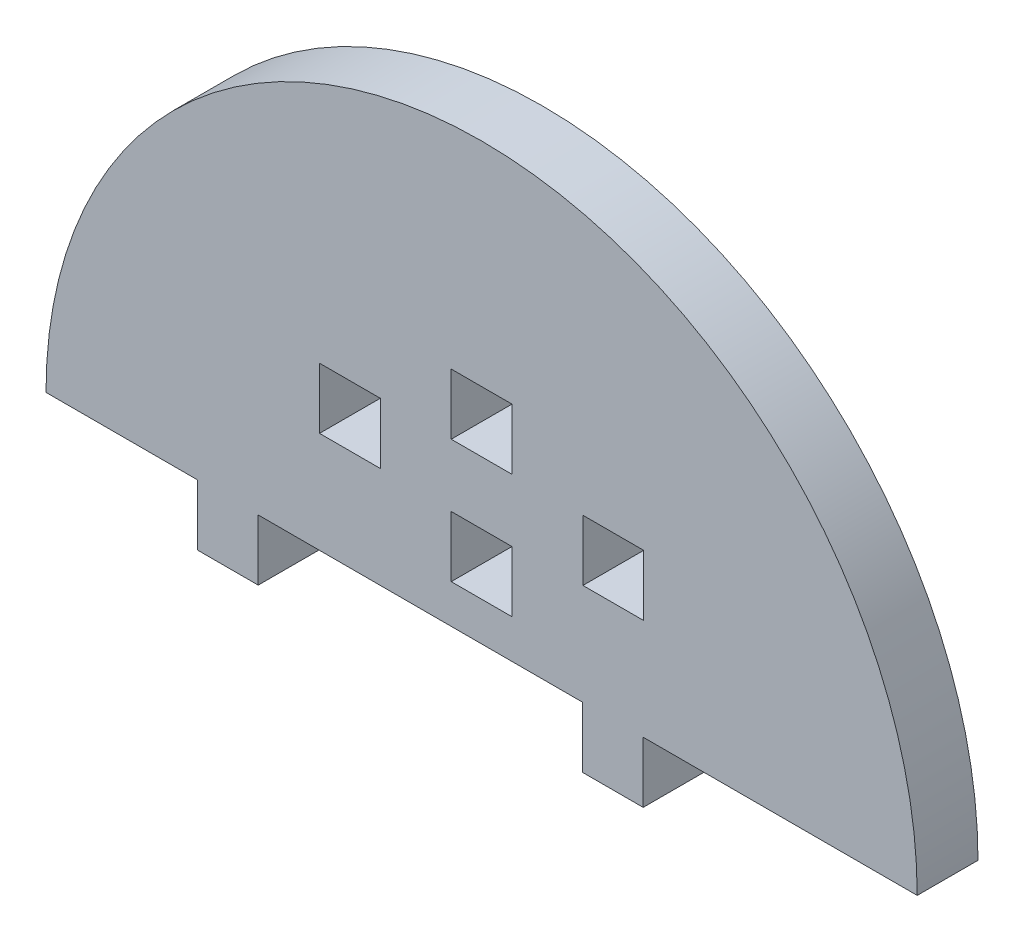
from build123d import *

# Parameters (mm, degrees)
MODEL_W             = 6
MODEL_H             = 6
BOSS_EXTRUDE1_DEPTH = 6


with BuildPart() as part:
    # Model → Boss-Extrude1 (new body)
    with BuildSketch(Plane.XY):
        with BuildLine():
            Line((3463.892984012, 1061.748947436), (3473.892984012, 1061.748947436))
            Line((3473.892984012, 1061.748947436), (3473.892984012, 1055.748947436))
            Line((3473.892984012, 1055.748947436), (3479.892984012, 1055.748947436))
            Line((3479.892984012, 1055.748947436), (3479.892984012, 1061.748947436))
            Line((3479.892984012, 1061.748947436), (3491.892984012, 1061.748947436))
            Line((3491.892984012, 1061.748947436), (3506.94434904, 1061.748947436))
            ThreePointArc((3506.94434904, 1061.748947436), (3463.94434904, 1104.748947436), (3420.94434904, 1061.748947436))
            Line((3420.94434904, 1061.748947436), (3435.892984012, 1061.748947436))
            Line((3435.892984012, 1061.748947436), (3435.892984012, 1055.748947436))
            Line((3435.892984012, 1055.748947436), (3441.892984012, 1055.748947436))
            Line((3441.892984012, 1055.748947436), (3441.892984012, 1061.748947436))
            Line((3441.892984012, 1061.748947436), (3463.892984012, 1061.748947436))
        make_face()
        with Locations((3476.94434904, 1074.748947436)):
            Rectangle(MODEL_W, MODEL_H, mode=Mode.SUBTRACT)
        with Locations((3450.94434904, 1074.748947436)):
            Rectangle(MODEL_W, MODEL_H, mode=Mode.SUBTRACT)
        with Locations((3463.94434904, 1080.748947436)):
            Rectangle(MODEL_W, MODEL_H, mode=Mode.SUBTRACT)
        with Locations((3463.94434904, 1068.57340627)):
            Rectangle(MODEL_W, MODEL_H, mode=Mode.SUBTRACT)
    extrude(amount=BOSS_EXTRUDE1_DEPTH)


solid = part.part
